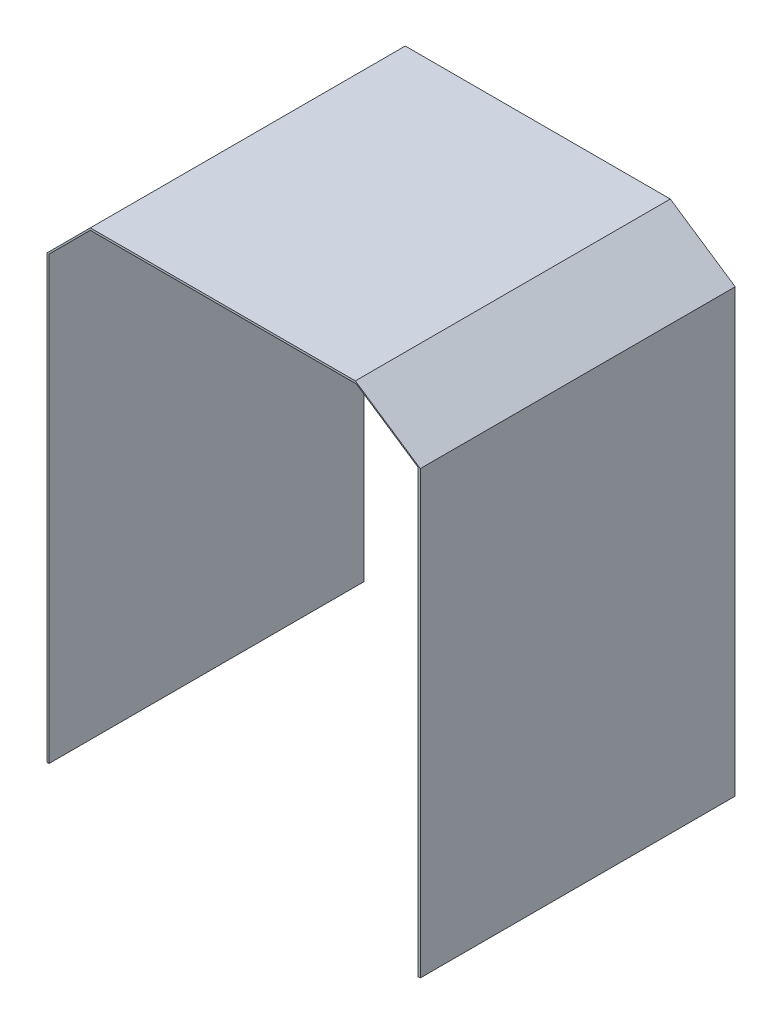
from build123d import *

# Parameters (mm, degrees)
BOSS_EXTRUDE1_DEPTH = 32.2


with BuildPart() as part:
    # Sketch1 → Boss-Extrude1 (new body)
    with BuildSketch(Plane.XY):
        Polygon((0, 0), (0, 45.1), (4.450602869, 49.550602869), (31.547374035, 49.550602869), (38.183613829, 45.1), (38.183613829, 0), (37.963613829, 0), (37.963613829, 45.1), (31.655413358, 49.330602869), (4.450602869, 49.330602869), (0.22, 45.1), (0.22, 0), align=None)
    extrude(amount=BOSS_EXTRUDE1_DEPTH)


solid = part.part
